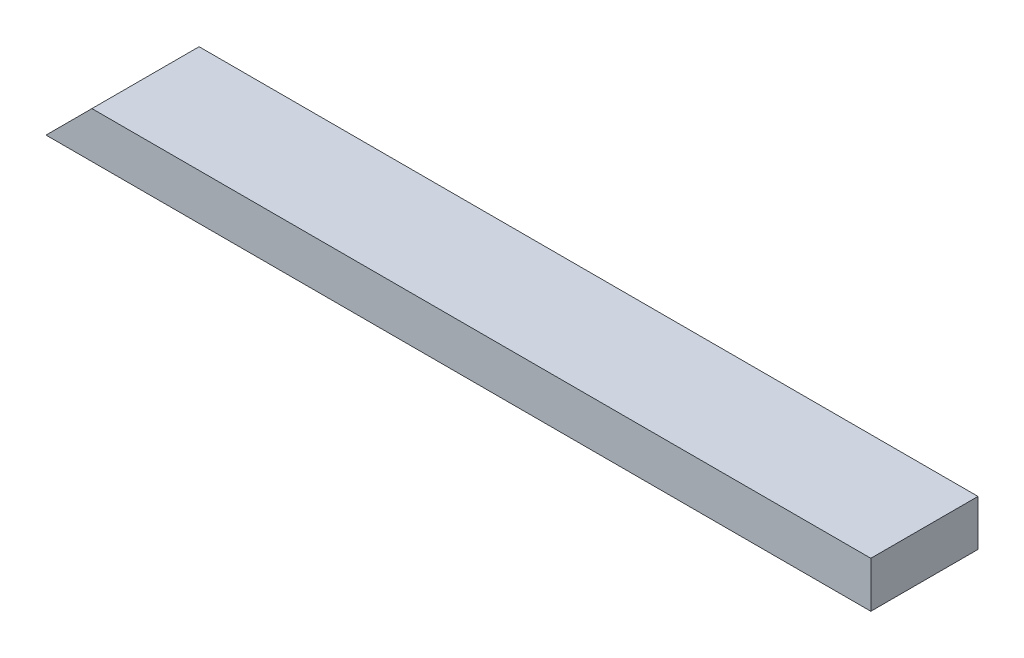
from build123d import *

# Parameters (mm, degrees)
SKETCH1_W           = 684.24425
SKETCH1_H           = 88.9
BOSS_EXTRUDE1_DEPTH = 38.1
CUT_EXTRUDE1_DEPTH  = 89.9


with BuildPart() as part:
    # Sketch1 → Boss-Extrude1 (new body)
    with BuildSketch(Plane(origin=(0, 0, 0), x_dir=(1, 0, 0), z_dir=(0, 1, 0))):
        with Locations((342.122125, 44.45)):
            Rectangle(SKETCH1_W, SKETCH1_H)
    extrude(amount=BOSS_EXTRUDE1_DEPTH)

    # Sketch2 → Cut-Extrude1 (cut, through all)
    with BuildSketch(Plane.XY):
        Polygon((0, 0), (38.1, 38.1), (0, 38.1), align=None)
    extrude(amount=-CUT_EXTRUDE1_DEPTH, mode=Mode.SUBTRACT)


solid = part.part
